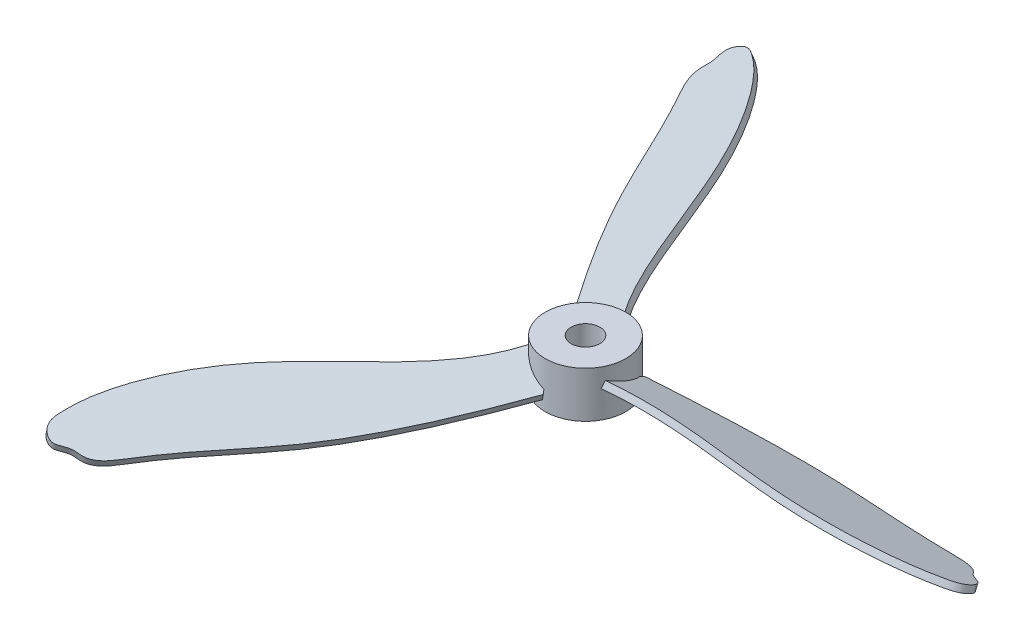
from build123d import *

# Parameters (mm, degrees)
BOSS_EXTRUDE1_DEPTH      = 4
BOSS_EXTRUDE1_DEPTH_BACK = 4
SKETCH1_R                = 7
SKETCH1_R_2              = 2.5
BOSS_EXTRUDE2_DEPTH      = 0.6
CIRPATTERN1_COUNT        = 3


with BuildPart() as part:
    # Sketch1 → Boss-Extrude1 (new, two sides: drawn at the far end of the back side and taken through both)
    with BuildSketch(Plane(origin=(0, 0, 0), x_dir=(1, 0, 0), z_dir=(0, 1, 0)).offset(-BOSS_EXTRUDE1_DEPTH_BACK)):
        Circle(SKETCH1_R)
        Circle(SKETCH1_R_2, mode=Mode.SUBTRACT)
    extrude(amount=BOSS_EXTRUDE1_DEPTH + BOSS_EXTRUDE1_DEPTH_BACK)

    # Sketch2 → Boss-Extrude2 (add, symmetric)
    with BuildSketch(Plane(origin=(0, 0, 0), x_dir=(-1, 0, 0), z_dir=(0, -0.9238795325112867, 0.3826834323650899))):
        with BuildLine():
            Line((-6.442641243, 4.059595346), (-3.51941234, -4.059595346))
            add(Edge.make_bspline(
                [(-6.442641243, 4.059595346), (-16.850129529, 5.362025567), (-35.279289062, 7.053736436), (-53.283157556, 3.870478554), (-64.015499337, 4.068183101), (-65.905092147, 1.050324171), (-68.424048708, 0.531195594), (-68.267888795, -2.774611905), (-63.959846606, -5.101413975), (-54.68790802, -7.421153474), (-33.351144776, -7.495092137), (-15.573723222, -0.617015244), (-3.51941234, -4.059595346)],
                knots=[0, 0, 0, 0, 0.246202511, 0.401236662, 0.448756169, 0.459405019, 0.479964886, 0.497385718, 0.519084515, 0.584945871, 0.719402984, 1, 1, 1, 1], degree=3))
        make_face()
    boss_extrude2 = extrude(amount=BOSS_EXTRUDE2_DEPTH, both=True)

    # CirPattern1: Boss-Extrude2 ×3 about axis
    cirpattern1_axis = Axis((0, -4, 0), (0, 1, 0))
    for i in range(1, CIRPATTERN1_COUNT):
        add(boss_extrude2.rotate(cirpattern1_axis, i * 360 / CIRPATTERN1_COUNT))


solid = part.part
